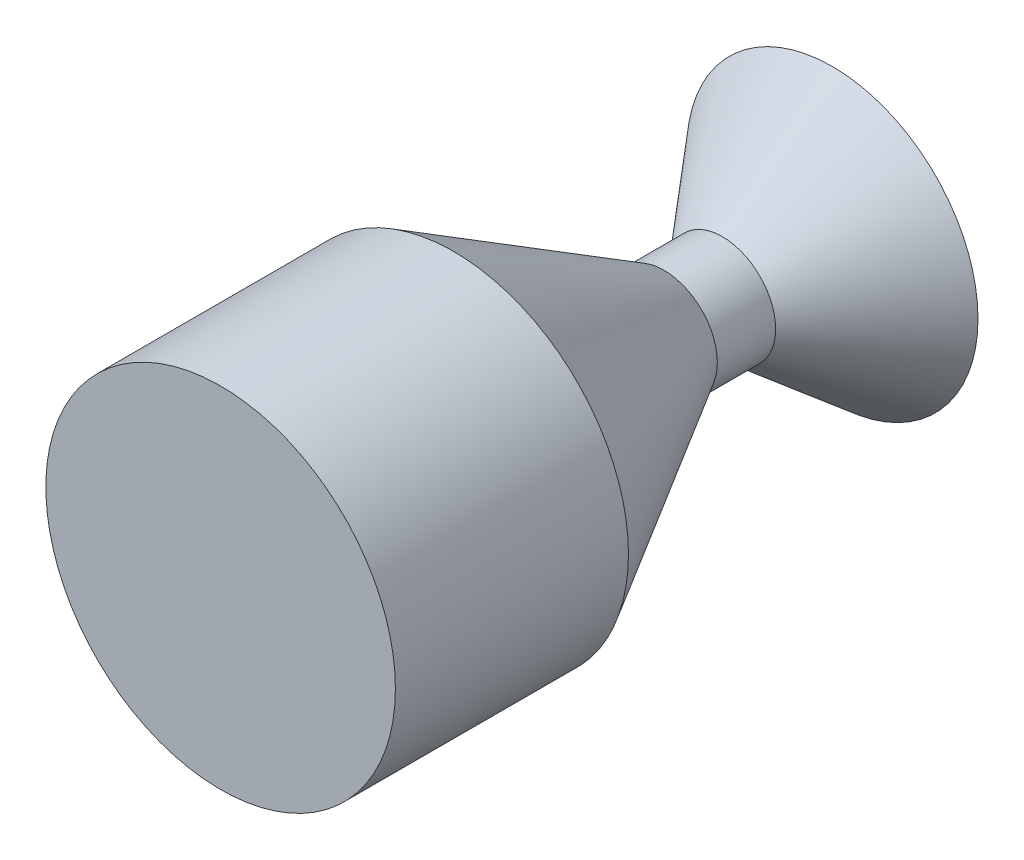
from build123d import *


with BuildPart() as part:
    # Sketch1 → Revolve1 (revolve)
    with BuildSketch(Plane(origin=(0, 0, 0), x_dir=(1, 0, 0), z_dir=(0, 1, 0))):
        Polygon((0, 0), (0, 105), (25, 105), (9.150873444, 86.111746488), (9.150873444, 76.111746488), (30, 40), (30, 0), align=None)
    revolve(axis=Axis((0, 0, 0), (0, 0, -1)))


solid = part.part
